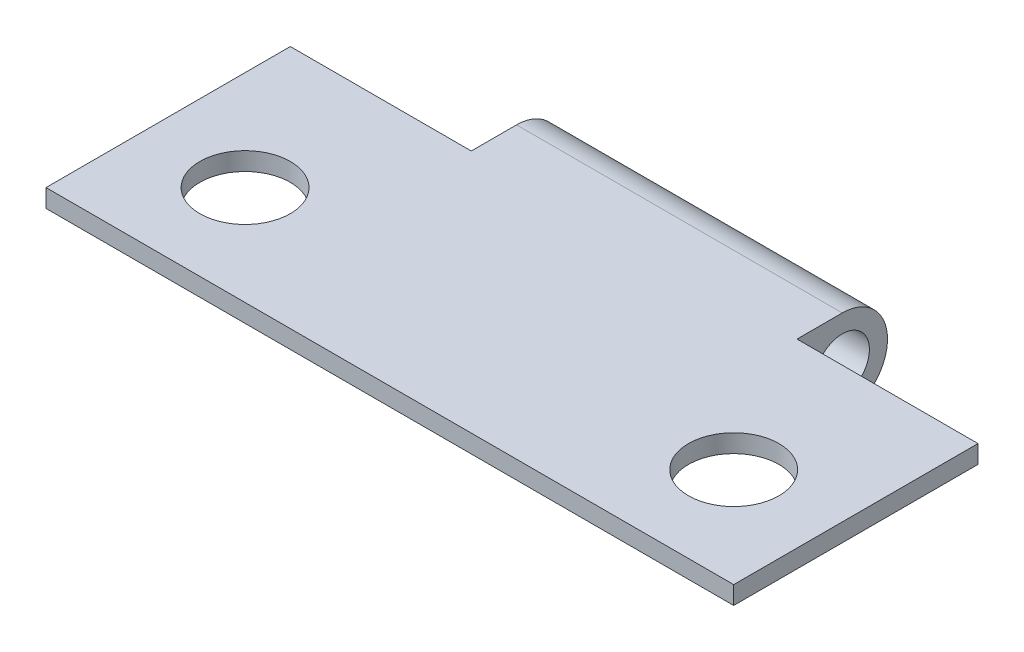
from build123d import *

# Parameters (mm, degrees)
SKETCH3_R           = 1.5
BOSS_EXTRUDE2_DEPTH = 38
SKETCH4_W           = 10
SKETCH4_H           = 5
CUT_EXTRUDE1_DEPTH  = 6
SKETCH5_R           = 2.5
CUT_EXTRUDE2_DEPTH  = 6


with BuildPart() as part:
    # Sketch3 → Boss-Extrude2 (new body)
    with BuildSketch(Plane(origin=(0, 0, 0), x_dir=(0, 0, -1), z_dir=(1, 0, 0))):
        with BuildLine():
            Line((16, 1), (0, 1))
            Line((0, 1), (0, 0))
            Line((0, 0), (14, 0))
            ThreePointArc((14, 0), (17.118033989, -3.736067977), (16, 1))
        make_face()
        with Locations((16, -1.5)):
            Circle(SKETCH3_R, mode=Mode.SUBTRACT)
    extrude(amount=BOSS_EXTRUDE2_DEPTH)

    # Sketch4 → Cut-Extrude1 (cut, through all)
    with BuildSketch(Plane(origin=(0, 1, 0), x_dir=(1, 0, 0), z_dir=(0, 1, 0))):
        with Locations((33, 16)):
            Rectangle(SKETCH4_W, SKETCH4_H)
        with Locations((5, 16)):
            Rectangle(SKETCH4_W, SKETCH4_H)
    extrude(amount=-CUT_EXTRUDE1_DEPTH, mode=Mode.SUBTRACT)

    # Sketch5 → Cut-Extrude2 (cut, through all)
    with BuildSketch(Plane(origin=(0, 1, 0), x_dir=(1, 0, 0), z_dir=(0, 1, 0))):
        with Locations((5.5, 5.5)):
            Circle(SKETCH5_R)
        with Locations((32.5, 5.5)):
            Circle(SKETCH5_R)
    extrude(amount=-CUT_EXTRUDE2_DEPTH, mode=Mode.SUBTRACT)


solid = part.part
